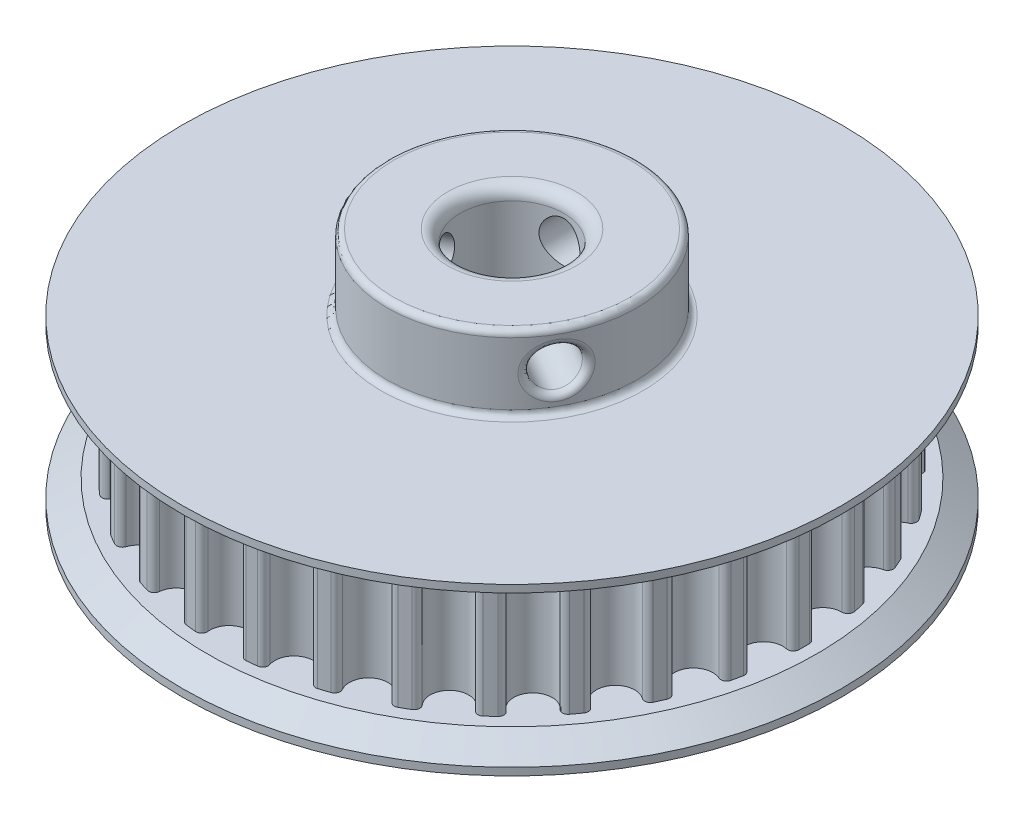
from build123d import *

# Parameters (mm, degrees)
BOSS_EXTRU_1_DEPTH           = 9.3
R_P_TITION_CIRCULAIRE1_COUNT = 30
ESQUISSE2_R                  = 26.4290252
BOSS_EXTRU_2_DEPTH           = 2
CHANFREIN1_SIZE              = 2
CHANFREIN1_SIZE2             = 1.400415076
CHANFREIN1_PART_2_SIZE       = 2
CHANFREIN1_PART_2_SIZE2      = 1.400415076
ESQUISSE4_R                  = 10
BOSS_EXTRU_3_DEPTH           = 6
ESQUISSE5_R                  = 1.65
ENL_V_MAT_EXTRU_2_DEPTH      = 27.4290252
R_P_TITION_CIRCULAIRE2_COUNT = 3
ENL_V_MAT_EXTRU_1_REACH      = 21.3
ESQUISSE3_R                  = 4.15
CONG_1_R                     = 1
CONG_2_R                     = 0.5


with BuildPart() as part:
    # Esquisse1 → Boss.-Extru.1 (new body)
    with BuildSketch(Plane(origin=(0, 0, 0), x_dir=(1, 0, 0), z_dir=(0, 1, 0))):
        with BuildLine():
            Line((0, 0), (-2.449, 23.300678548))
            ThreePointArc((-2.449, 23.300678548), (-2.23925905, 23.321769674), (-2.029336827, 23.340972856))
            ThreePointArc((-2.029336827, 23.340972856), (-1.662628217, 23.205334027), (-1.534260602, 22.83601729))
            ThreePointArc((-1.534260602, 22.83601729), (0, 21.1290252), (1.534260602, 22.83601729))
            ThreePointArc((1.534260602, 22.83601729), (1.662628217, 23.205334027), (2.029336827, 23.340972856))
            ThreePointArc((2.029336827, 23.340972856), (2.23925905, 23.321769674), (2.449, 23.300678548))
            Line((2.449, 23.300678548), (0, 0))
        make_face()
    boss_extru_1 = extrude(amount=BOSS_EXTRU_1_DEPTH)

    # Répétition circulaire1: Boss.-Extru.1 ×30 about axis
    r_p_tition_circulaire1_axis = Axis((0, 0, 0), (0, 1, 0))
    for i in range(1, R_P_TITION_CIRCULAIRE1_COUNT):
        add(boss_extru_1.rotate(r_p_tition_circulaire1_axis, i * 360 / R_P_TITION_CIRCULAIRE1_COUNT))

    # Esquisse2 → Boss.-Extru.2 (add)
    with BuildSketch(Plane(origin=(0, 9.3, 0), x_dir=(1, 0, 0), z_dir=(0, 1, 0))):
        Circle(ESQUISSE2_R)
    boss_extru_2 = extrude(amount=BOSS_EXTRU_2_DEPTH)

    # Symétrie1: Boss.-Extru.2 across plane
    add(boss_extru_2.mirror(Plane(origin=(0, 4.65, 0), x_dir=(0, 0, 1), z_dir=(0, -1, 0))))

    # Chanfrein1
    chanfrein1_edges = [part.edges().sort_by_distance(p)[0] for p in [
        (-26.4290252, 9.3, 0),
    ]]
    chanfrein1_side = [part.faces().sort_by_distance(p)[0] for p in [
        (-25.681499482, 9.3, 0),
    ]]
    chamfer(chanfrein1_edges, length=CHANFREIN1_SIZE, length2=CHANFREIN1_SIZE2, reference=chanfrein1_side[0])

    # Chanfrein1 part 2
    chanfrein1_part_2_edges = [part.edges().sort_by_distance(p)[0] for p in [
        (-26.4290252, 0, 0),
    ]]
    chanfrein1_part_2_side = [part.faces().sort_by_distance(p)[0] for p in [
        (-25.681499482, 0, 0),
    ]]
    chamfer(chanfrein1_part_2_edges, length=CHANFREIN1_PART_2_SIZE, length2=CHANFREIN1_PART_2_SIZE2, reference=chanfrein1_part_2_side[0])

    # Esquisse4 → Boss.-Extru.3 (add)
    with BuildSketch(Plane(origin=(0, 11.3, 0), x_dir=(1, 0, 0), z_dir=(0, 1, 0))):
        Circle(ESQUISSE4_R)
    extrude(amount=BOSS_EXTRU_3_DEPTH)

    # Esquisse5 → Enlèv. mat.-Extru.2 (cut, through all)
    with BuildSketch(Plane.XY):
        with Locations((0, 14.3)):
            Circle(ESQUISSE5_R)
    enl_v_mat_extru_2 = extrude(amount=-ENL_V_MAT_EXTRU_2_DEPTH, mode=Mode.SUBTRACT)

    # Répétition circulaire2: Enlèv. mat.-Extru.2 ×3 about axis
    r_p_tition_circulaire2_axis = Axis((0, 17.3, 0), (0, -1, 0))
    for i in range(1, R_P_TITION_CIRCULAIRE2_COUNT):
        add(enl_v_mat_extru_2.rotate(r_p_tition_circulaire2_axis, i * 360 / R_P_TITION_CIRCULAIRE2_COUNT), mode=Mode.SUBTRACT)

    # Esquisse3 → Enlèv. mat.-Extru.1 (cut, up to next)
    with BuildSketch(Plane(origin=(0, 17.3, 0), x_dir=(1, 0, 0), z_dir=(0, 1, 0)), mode=Mode.PRIVATE) as enl_v_mat_extru_1_sk1:
        Circle(ESQUISSE3_R)
    enl_v_mat_extru_1_tool1 = extrude(enl_v_mat_extru_1_sk1.sketch, amount=-ENL_V_MAT_EXTRU_1_REACH, mode=Mode.PRIVATE) & part.part
    add(enl_v_mat_extru_1_tool1.solids().sort_by_distance((0, 17.3, 0))[0], mode=Mode.SUBTRACT)

    # Congé1
    cong_1_edges = [part.edges().sort_by_distance(p)[0] for p in [
        (-4.15, -2, 0),
        (-4.15, 17.3, 0),
    ]]
    fillet(cong_1_edges, radius=CONG_1_R)

    # Congé2
    cong_2_edges = [part.edges().sort_by_distance(p)[0] for p in [
        (-10, 11.3, 0),
        (-10, 17.3, 0),
        (-1.650000023, 14.300000005, -9.862935666),
        (9.366552854, 14.300000005, 3.502525897),
        (-7.716552831, 14.300000005, 6.360409769),
    ]]
    fillet(cong_2_edges, radius=CONG_2_R)


solid = part.part
